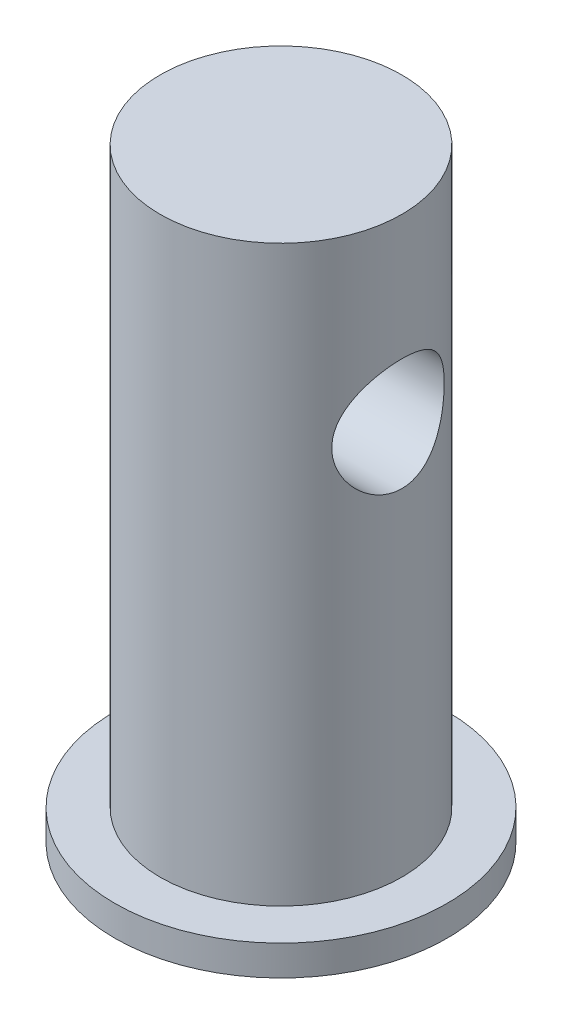
from build123d import *

# Parameters (mm, degrees)
SKETCH1_R           = 5.5
SKETCH1_R_2         = 4
BOSS_EXTRUDE1_DEPTH = 1
SKETCH1_2_R         = 4
BOSS_EXTRUDE2_DEPTH = 20
SKETCH2_R           = 1.8611768
CUT_EXTRUDE1_DEPTH  = 12


with BuildPart() as part:
    # Sketch1 → Boss-Extrude1 (new body)
    with BuildSketch(Plane(origin=(0, 0, 0), x_dir=(1, 0, 0), z_dir=(0, 1, 0))):
        Circle(SKETCH1_R)
        Circle(SKETCH1_R_2, mode=Mode.SUBTRACT)
    extrude(amount=BOSS_EXTRUDE1_DEPTH)

    # Sketch1_2 → Boss-Extrude2 (add)
    with BuildSketch(Plane(origin=(0, 0, 0), x_dir=(1, 0, 0), z_dir=(0, 1, 0))):
        Circle(SKETCH1_2_R)
    extrude(amount=BOSS_EXTRUDE2_DEPTH)

    # Sketch2 → Cut-Extrude1 (cut)
    with BuildSketch(Plane(origin=(4, 0, 0), x_dir=(0, 0, -1), z_dir=(1, 0, 0))):
        with Locations((0, 14)):
            Circle(SKETCH2_R)
    extrude(amount=-CUT_EXTRUDE1_DEPTH, mode=Mode.SUBTRACT)


solid = part.part
